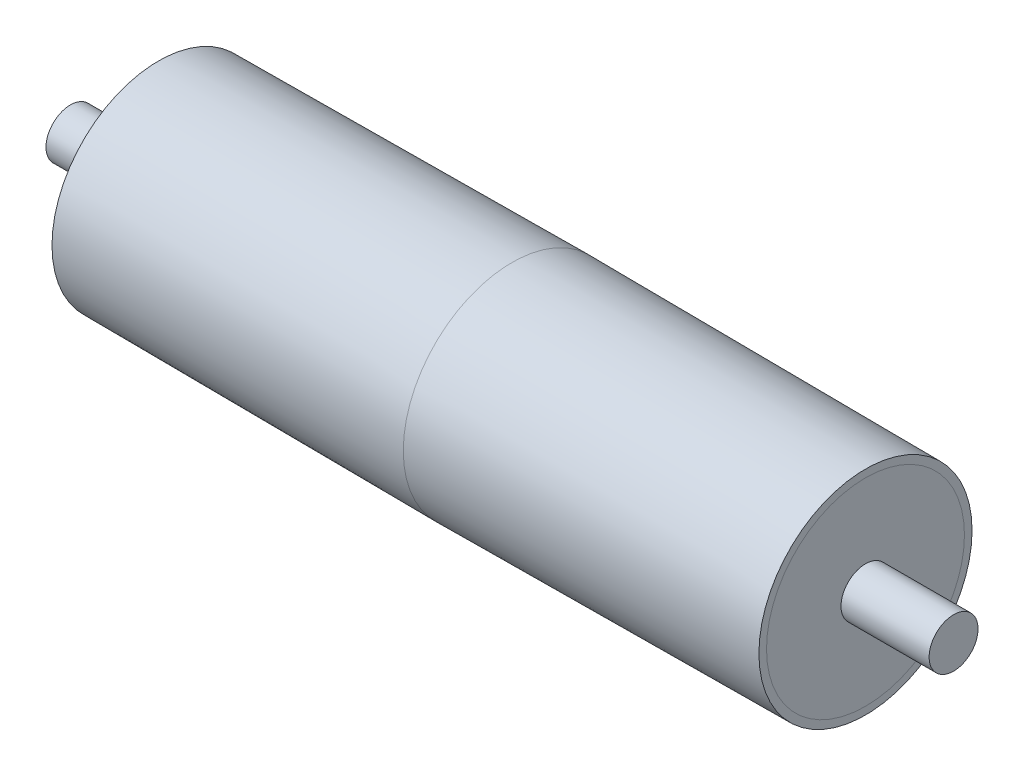
from build123d import *

# Parameters (mm, degrees)
SHELL1_T            = -7
SKETCH2_R           = 90.999867457
BOSS_EXTRUDE1_DEPTH = 10
SKETCH3_R           = 22.5
CUT_EXTRUDE1_DEPTH  = 735
SKETCH4_R           = 22.5
BOSS_EXTRUDE2_DEPTH = 406


with BuildPart() as part:
    # Sketch1 → Revolve1 (revolve)
    with BuildSketch(Plane.XY, mode=Mode.PRIVATE) as revolve1_sk:
        Polygon((-325, 98), (0, 100), (325, 98), (325, 0), (-325, 0), align=None)
    revolve(revolve1_sk.sketch.rotate(Axis((-325, 0, 0), (1, 0, 0)), 90), axis=Axis((-325, 0, 0), (1, 0, 0)))

    # Shell1
    shell1_openings = [part.faces().sort_by_distance(p)[0] for p in [
        (325, 0, 0),
        (-325, 0, 0),
    ]]
    offset(amount=SHELL1_T, openings=shell1_openings)


with BuildPart() as body_2:
    # Sketch2 → Boss-Extrude1 (new body)
    with BuildSketch(Plane(origin=(325, 0, 0), x_dir=(0, 0, -1), z_dir=(1, 0, 0))):
        Circle(SKETCH2_R)
    extrude(amount=-BOSS_EXTRUDE1_DEPTH)


with BuildPart() as body_3:
    # Mirror2: mirrored copy
    add(body_2.part.mirror(Plane(origin=(0, 0, 0), x_dir=(0, 0, 1), z_dir=(1, 0, 0))))


with BuildPart() as cut_extrude1_tool:
    # Sketch3 → Cut-Extrude1 (new body)
    with BuildSketch(Plane(origin=(325, 0, 0), x_dir=(0, 0, -1), z_dir=(1, 0, 0))):
        with Locations(Location((0, 0, 0), (0, 0, 180))):
            Circle(SKETCH3_R)
    extrude(amount=-CUT_EXTRUDE1_DEPTH)


with BuildPart() as body_2_1:
    add(body_2.part)

    # Cut-Extrude1: cut by cut_extrude1_tool
    add(cut_extrude1_tool.part, mode=Mode.SUBTRACT)


with BuildPart() as body_3_1:
    add(body_3.part)

    # Cut-Extrude1: cut by cut_extrude1_tool
    add(cut_extrude1_tool.part, mode=Mode.SUBTRACT)


with BuildPart() as body_4:
    # Sketch4 → Boss-Extrude2 (new, symmetric)
    with BuildSketch(Plane(origin=(0, 0, 0), x_dir=(0, 0, -1), z_dir=(1, 0, 0))):
        with Locations(Location((0, 0, 0), (0, 0, 180))):
            Circle(SKETCH4_R)
    extrude(amount=BOSS_EXTRUDE2_DEPTH, both=True)


solid = Compound([part.part, body_2_1.part, body_3_1.part, body_4.part])
